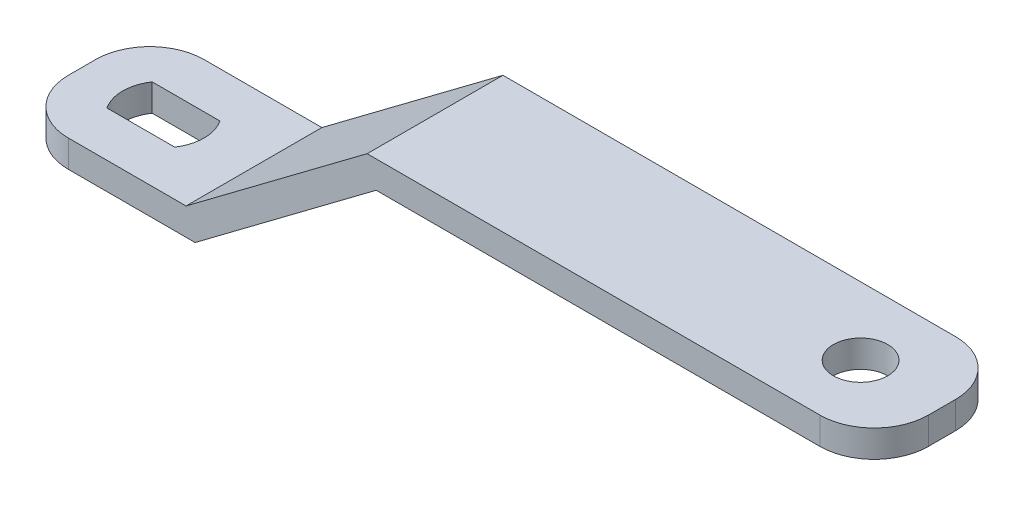
from build123d import *

# Parameters (mm, degrees)
BOSS_EXTRU_1_DEPTH      = 15
ESQUISSE3_OUTSIDE_W     = 116.57
ESQUISSE3_OUTSIDE_H     = 36.57
ESQUISSE3_OUTSIDE_R     = 3
ENL_V_MAT_EXTRU_1_DEPTH = 19


with BuildPart() as part:
    # Esquisse1 → Boss.-Extru.1 (new body)
    with BuildSketch(Plane.XY):
        Polygon((0, 0), (20, 0), (40, 15), (95, 15), (95, 18), (39, 18), (19, 3), (0, 3), align=None)
    extrude(amount=BOSS_EXTRU_1_DEPTH)

    # Esquisse3 outside → Enlèv. mat.-Extru.1 (cut, through all)
    with BuildSketch(Plane(origin=(0, 18, 0), x_dir=(1, 0, 0), z_dir=(0, 1, 0))):
        with Locations((47.5, -7.5)):
            Rectangle(ESQUISSE3_OUTSIDE_W, ESQUISSE3_OUTSIDE_H)
        with BuildLine():
            Line((6, 0), (89, 0))
            ThreePointArc((89, 0), (93.242640687, -1.757359313), (95, -6))
            Line((95, -6), (95, -9))
            ThreePointArc((95, -9), (93.242640687, -13.242640687), (89, -15))
            Line((89, -15), (6, -15))
            ThreePointArc((6, -15), (1.757359313, -13.242640687), (0, -9))
            Line((0, -9), (0, -6))
            ThreePointArc((0, -6), (1.757359313, -1.757359313), (6, 0))
        make_face(mode=Mode.SUBTRACT)
        with Locations((86, -7.5)):
            Circle(ESQUISSE3_OUTSIDE_R)
        with BuildLine():
            Line((5.258342613, -5), (12.741657387, -5))
            ThreePointArc((12.741657387, -5), (13.5, -7.5), (12.741657387, -10))
            Line((12.741657387, -10), (5.258342613, -10))
            ThreePointArc((5.258342613, -10), (4.5, -7.5), (5.258342613, -5))
        make_face()
    extrude(amount=-ENL_V_MAT_EXTRU_1_DEPTH, mode=Mode.SUBTRACT)


solid = part.part
